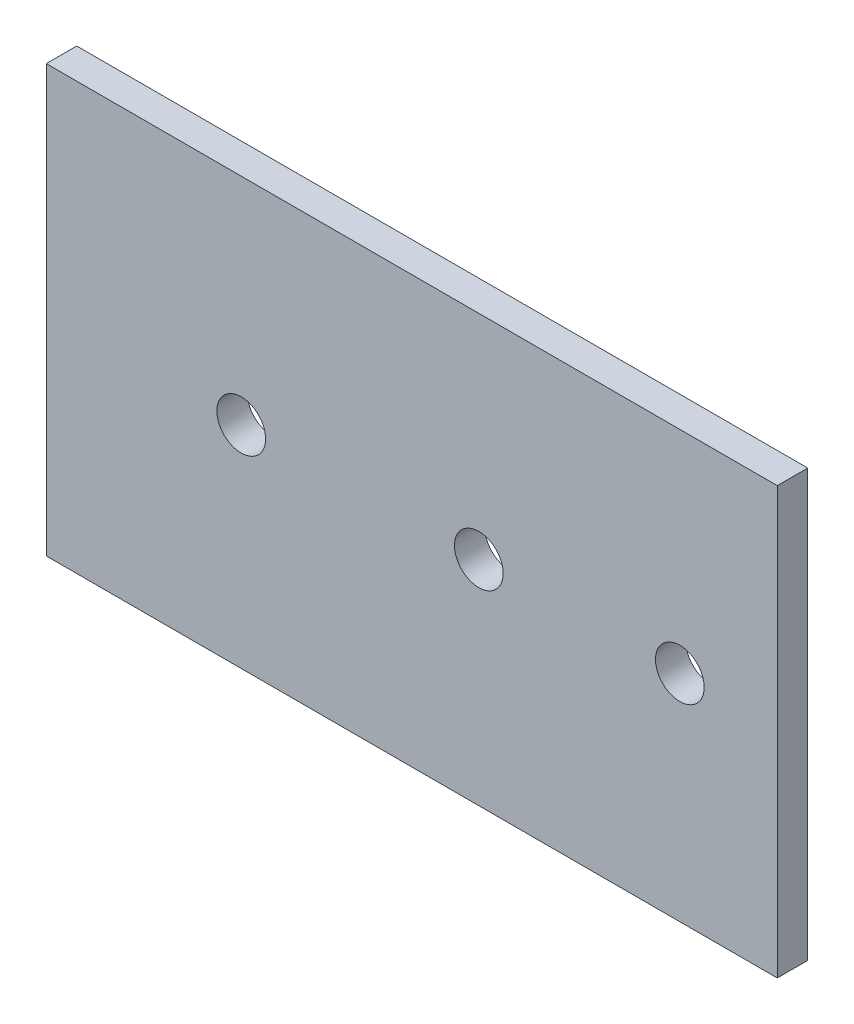
from build123d import *

# Parameters (mm, degrees)
SKETCH1_W           = 150
SKETCH1_H           = 70
BOSS_EXTRUDE1_DEPTH = 2.5
SKETCH2_R           = 4
CUT_EXTRUDE1_DEPTH  = 6
SKETCH3_W           = 30
SKETCH3_H           = 70
CUT_EXTRUDE2_DEPTH  = 6


with BuildPart() as part:
    # Sketch1 → Boss-Extrude1 (new body, symmetric)
    with BuildSketch(Plane.XY):
        Rectangle(SKETCH1_W, SKETCH1_H)
    extrude(amount=BOSS_EXTRUDE1_DEPTH, both=True)

    # Sketch2 → Cut-Extrude1 (cut, through all)
    with BuildSketch(Plane.XY.offset(2.5)):
        with Locations((63, 0.628549325)):
            Circle(SKETCH2_R)
        with Locations((29.001496193, 0.309583996)):
            Circle(SKETCH2_R)
        with Locations((-42.995335398, -0.365871995)):
            Circle(SKETCH2_R)
        with Locations((-3.99705162, 0)):
            Circle(SKETCH2_R)
    extrude(amount=-CUT_EXTRUDE1_DEPTH, mode=Mode.SUBTRACT)

    # Sketch3 → Cut-Extrude2 (cut, through all)
    with BuildSketch(Plane.XY.offset(2.5)):
        with Locations((60, 0)):
            Rectangle(SKETCH3_W, SKETCH3_H)
    extrude(amount=-CUT_EXTRUDE2_DEPTH, mode=Mode.SUBTRACT)


solid = part.part
